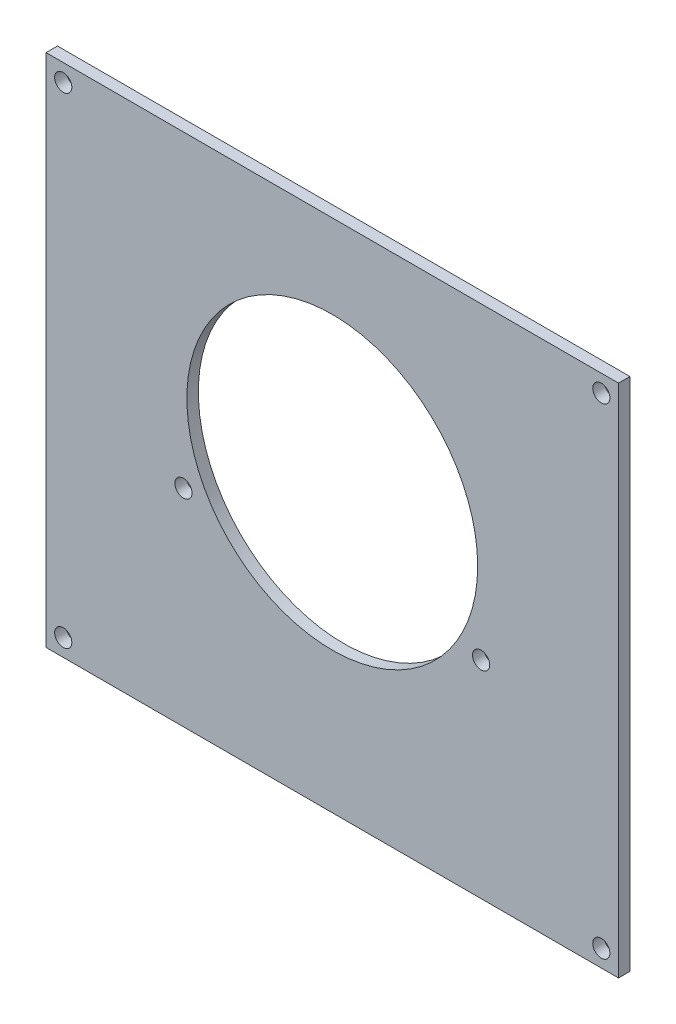
from build123d import *

# Parameters (mm, degrees)
SKETCH1_W                                         = 100
SKETCH1_H                                         = 90
BOSS_EXTRUDE1_DEPTH                               = 2
SKETCH2_R                                         = 25.4
CUT_EXTRUDE1_DEPTH                                = 3
SKETCH3_R                                         = 1.5
CUT_EXTRUDE2_DEPTH                                = 3
SKETCH4_R                                         = 1.5
CUT_EXTRUDE3_DEPTH                                = 10
CSK_FOR_0_FLAT_HEAD_MACHINE_SCREW_100_D           = 1.778
CSK_FOR_0_FLAT_HEAD_MACHINE_SCREW_100_CSINK_D     = 3.0226
CSK_FOR_0_FLAT_HEAD_MACHINE_SCREW_100_CSINK_ANGLE = 100


with BuildPart() as part:
    # Sketch1 → Boss-Extrude1 (new body)
    with BuildSketch(Plane.XY):
        with Locations((-26.224709151, 41.314420924)):
            Rectangle(SKETCH1_W, SKETCH1_H)
    extrude(amount=BOSS_EXTRUDE1_DEPTH)

    # Sketch2 → Cut-Extrude1 (cut)
    with BuildSketch(Plane.XY.offset(2)):
        with Locations((-26.224709151, 46.314420924)):
            Circle(SKETCH2_R)
    extrude(amount=-CUT_EXTRUDE1_DEPTH, mode=Mode.SUBTRACT)

    # Sketch3 → Cut-Extrude2 (cut)
    with BuildSketch(Plane.XY.offset(2)):
        with Locations((-52.224709151, 32.414420924)):
            Circle(SKETCH3_R)
        with Locations((-0.224709151, 32.414420924)):
            Circle(SKETCH3_R)
    extrude(amount=-CUT_EXTRUDE2_DEPTH, mode=Mode.SUBTRACT)

    # Sketch4 → Cut-Extrude3 (cut)
    with BuildSketch(Plane(origin=(0, 0, 0), x_dir=(-1, 0, 0), z_dir=(0, 0, -1))):
        with Locations((-20.775290849, 83.314420924)):
            Circle(SKETCH4_R)
        with Locations((73.224709151, 83.314420924)):
            Circle(SKETCH4_R)
        with Locations((73.224709151, -0.685579076)):
            Circle(SKETCH4_R)
        with Locations((-20.775290849, -0.685579076)):
            Circle(SKETCH4_R)
    extrude(amount=-CUT_EXTRUDE3_DEPTH, mode=Mode.SUBTRACT)

    # CSK for #0 Flat Head Machine Screw (100)2 (through all)
    with Locations(Plane(origin=(0, 0, 0), x_dir=(-1, 0, 0), z_dir=(0, 0, -1))):
        with Locations((-20.775290849, 83.314420924), (73.224709151, 83.314420924), (73.224709151, -0.685579076), (-20.775290849, -0.685579076)):
            CounterSinkHole(CSK_FOR_0_FLAT_HEAD_MACHINE_SCREW_100_D / 2, CSK_FOR_0_FLAT_HEAD_MACHINE_SCREW_100_CSINK_D / 2, counter_sink_angle=CSK_FOR_0_FLAT_HEAD_MACHINE_SCREW_100_CSINK_ANGLE)


solid = part.part
